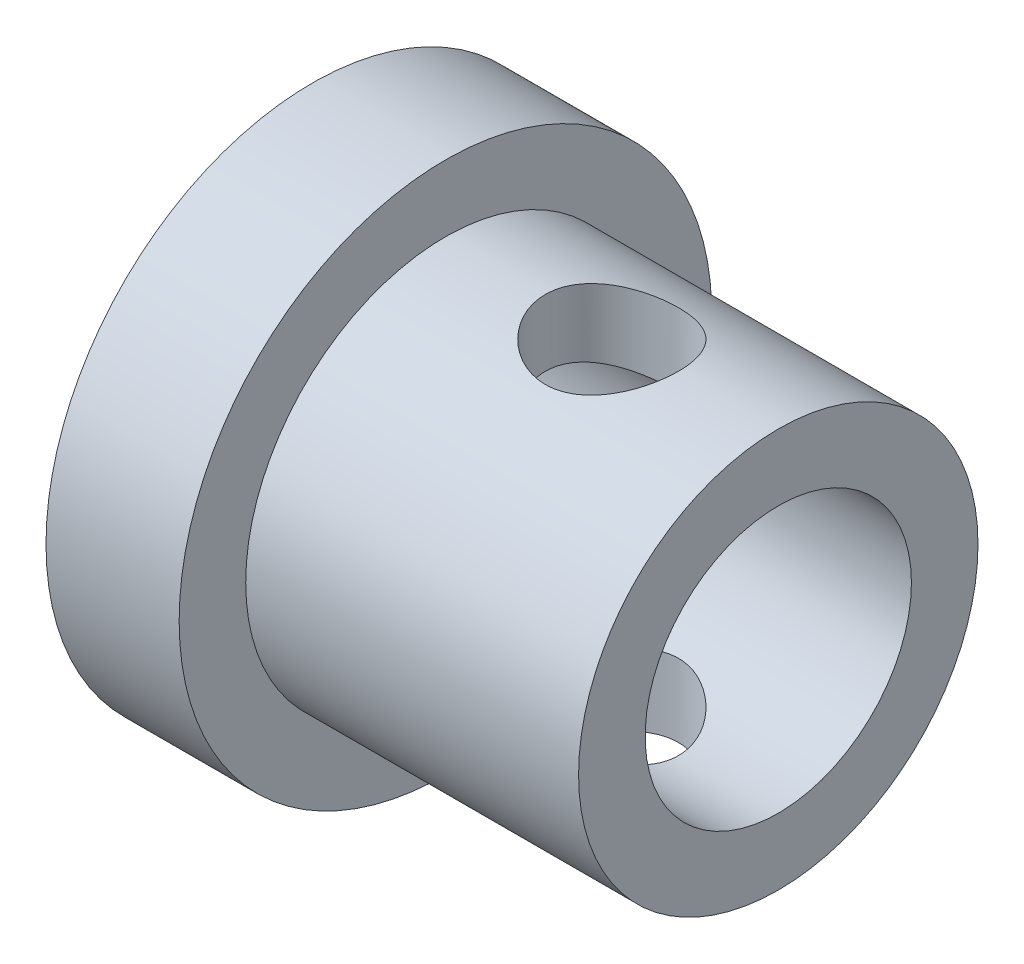
from build123d import *

# Parameters (mm, degrees)
SKETCH1_R               = 3
BOSS_EXTRUDE1_DEPTH     = 3.5
SKETCH2_R               = 4
BOSS_EXTRUDE2_DEPTH     = 2
SKETCH3_R               = 2
CUT_EXTRUDE1_DEPTH      = 8
SKETCH4_R               = 1
CUT_EXTRUDE2_DEPTH      = 5
CUT_EXTRUDE2_DEPTH_BACK = 5


with BuildPart() as part:
    # Sketch1 → Boss-Extrude1 (new body, symmetric)
    with BuildSketch(Plane(origin=(0, 0, 0), x_dir=(0, 0, -1), z_dir=(1, 0, 0))):
        Circle(SKETCH1_R)
    extrude(amount=BOSS_EXTRUDE1_DEPTH, both=True)

    # Sketch2 → Boss-Extrude2 (add)
    with BuildSketch(Plane.ZY.offset(3.5)):
        Circle(SKETCH2_R)
    extrude(amount=-BOSS_EXTRUDE2_DEPTH)

    # Sketch3 → Cut-Extrude1 (cut, through all)
    with BuildSketch(Plane(origin=(3.5, 0, 0), x_dir=(0, 0, -1), z_dir=(1, 0, 0))):
        Circle(SKETCH3_R)
    extrude(amount=-CUT_EXTRUDE1_DEPTH, mode=Mode.SUBTRACT)

    # Sketch4 → Cut-Extrude2 (cut, two sides)
    with BuildSketch(Plane(origin=(0, 0, 0), x_dir=(1, 0, 0), z_dir=(0, 1, 0))) as cut_extrude2_sk:
        with Locations((1, 0)):
            Circle(SKETCH4_R)
    extrude(amount=CUT_EXTRUDE2_DEPTH, mode=Mode.SUBTRACT)
    extrude(cut_extrude2_sk.sketch, amount=-CUT_EXTRUDE2_DEPTH_BACK, mode=Mode.SUBTRACT)


solid = part.part
